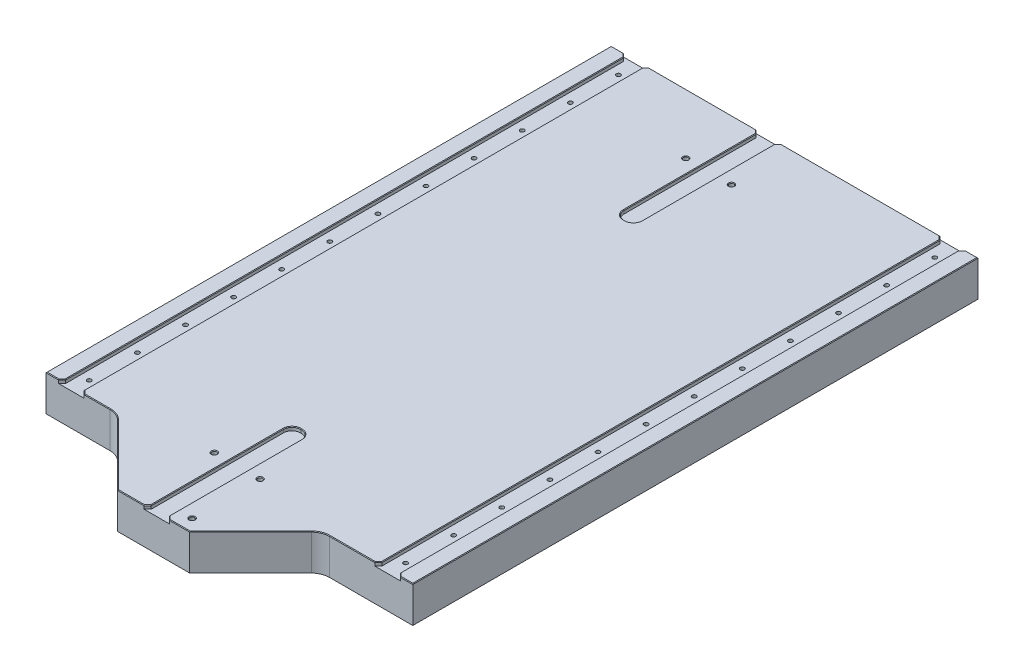
from build123d import *

# Parameters (mm, degrees)
BOSS_EXTRUDE1_DEPTH = 30
SKETCH2_R           = 1.75
SKETCH2_R_2         = 2
CUT_EXTRUDE1_DEPTH  = 31
SKETCH3_W           = 15.25
SKETCH3_H           = 470
CUT_EXTRUDE2_DEPTH  = 3
SKETCH4_W           = 15
SKETCH4_H           = 120
CUT_EXTRUDE3_DEPTH  = 3
FILLET1_R           = 7
FILLET2_R           = 15
CHAMFER1_SIZE       = 3
CHAMFER2_SIZE       = 0.5


with BuildPart() as part:
    # Sketch1 → Boss-Extrude1 (new body)
    with BuildSketch(Plane(origin=(0, 0, 0), x_dir=(1, 0, 0), z_dir=(0, 1, 0))):
        Polygon((-93, -235), (-38, -290), (22, -290), (77, -235), (152.5, -235), (152.5, 235), (-152.5, 235), (-152.5, -235), align=None)
    extrude(amount=BOSS_EXTRUDE1_DEPTH)

    # Sketch2 → Cut-Extrude1 (cut, through all)
    with BuildSketch(Plane(origin=(0, 0, 0), x_dir=(1, 0, 0), z_dir=(0, 1, 0))):
        with Locations((-131.5, 220)):
            Circle(SKETCH2_R)
        with Locations((131.5, 220)):
            Circle(SKETCH2_R)
        with Locations((13.5, -223)):
            Circle(SKETCH2_R_2)
        with Locations((-24.5, -223)):
            Circle(SKETCH2_R_2)
        with Locations((-40.5, 185)):
            Circle(SKETCH2_R_2)
        with Locations((-2.5, 185)):
            Circle(SKETCH2_R_2)
        with Locations((-131.5, 180)):
            Circle(SKETCH2_R)
        with Locations((131.5, 180)):
            Circle(SKETCH2_R)
        with Locations((-131.5, 140)):
            Circle(SKETCH2_R)
        with Locations((131.5, 140)):
            Circle(SKETCH2_R)
        with Locations((-131.5, 100)):
            Circle(SKETCH2_R)
        with Locations((131.5, 100)):
            Circle(SKETCH2_R)
        with Locations((-131.5, 60)):
            Circle(SKETCH2_R)
        with Locations((131.5, 60)):
            Circle(SKETCH2_R)
        with Locations((-131.5, 20)):
            Circle(SKETCH2_R)
        with Locations((131.5, 20)):
            Circle(SKETCH2_R)
        with Locations((-131.5, -20)):
            Circle(SKETCH2_R)
        with Locations((131.5, -20)):
            Circle(SKETCH2_R)
        with Locations((-131.5, -60)):
            Circle(SKETCH2_R)
        with Locations((131.5, -60)):
            Circle(SKETCH2_R)
        with Locations((-131.5, -100)):
            Circle(SKETCH2_R)
        with Locations((131.5, -100)):
            Circle(SKETCH2_R)
        with Locations((-131.5, -140)):
            Circle(SKETCH2_R)
        with Locations((131.5, -140)):
            Circle(SKETCH2_R)
        with Locations((-131.5, -180)):
            Circle(SKETCH2_R)
        with Locations((131.5, -180)):
            Circle(SKETCH2_R)
        with Locations((-131.5, -220)):
            Circle(SKETCH2_R)
        with Locations((131.5, -220)):
            Circle(SKETCH2_R)
        with Locations((13.5, -279.5)):
            Circle(SKETCH2_R_2)
    extrude(amount=CUT_EXTRUDE1_DEPTH, mode=Mode.SUBTRACT)

    # Sketch3 → Cut-Extrude2 (cut)
    with BuildSketch(Plane(origin=(0, 30, 0), x_dir=(1, 0, 0), z_dir=(0, 1, 0))):
        with Locations((-131.5, 0)):
            Rectangle(SKETCH3_W, SKETCH3_H)
        with Locations((131.5, 0)):
            Rectangle(SKETCH3_W, SKETCH3_H)
    extrude(amount=-CUT_EXTRUDE2_DEPTH, mode=Mode.SUBTRACT)

    # Sketch4 → Cut-Extrude3 (cut)
    with BuildSketch(Plane(origin=(0, 30, 0), x_dir=(1, 0, 0), z_dir=(0, 1, 0))):
        with Locations((-5.5, -230)):
            Rectangle(SKETCH4_W, SKETCH4_H)
        with Locations((-21.5, 175)):
            Rectangle(SKETCH4_W, SKETCH4_H)
    extrude(amount=-CUT_EXTRUDE3_DEPTH, mode=Mode.SUBTRACT)

    # Fillet1
    fillet1_edges = [part.edges().sort_by_distance(p)[0] for p in [
        (-13, 28.5, 170),
        (2, 28.5, 170),
        (-29, 28.5, -115),
        (-14, 28.5, -115),
    ]]
    fillet(fillet1_edges, radius=FILLET1_R)

    # Fillet2
    fillet2_edges = [part.edges().sort_by_distance(p)[0] for p in [
        (77, 15, 235),
        (-93, 15, 235),
    ]]
    fillet(fillet2_edges, radius=FILLET2_R)

    # Chamfer1
    chamfer1_edges = [part.edges().sort_by_distance(p)[0] for p in [
        (-123.875, 28.5, -235),
        (-123.875, 28.5, 235),
        (-139.125, 28.5, 235),
        (-139.125, 28.5, -235),
        (123.875, 28.5, 235),
        (123.875, 28.5, -235),
        (139.125, 28.5, -235),
        (139.125, 28.5, 235),
        (-13, 28.5, 290),
        (2, 28.5, 290),
        (-29, 28.5, -235),
        (-14, 28.5, -235),
    ]]
    chamfer(chamfer1_edges, length=CHAMFER1_SIZE)

    # Chamfer2
    chamfer2_edges = [part.edges().sort_by_distance(p)[0] for p in [
        (-152.5, 30, 0),
        (-147.3125, 30, 235),
        (-27, 30, 290),
        (47.303300859, 30, 264.696699141),
        (-21.5, 30, -115),
        (-14, 30, -177),
        (-13, 30, 232),
        (-5.5, 30, 170),
        (-26.949747468, 30, -117.050252532),
        (-16.050252532, 30, -117.050252532),
        (-10.949747468, 30, 172.050252532),
        (-0.050252532, 30, 172.050252532),
        (102.044101718, 30, 235),
        (-63.303300859, 30, 264.696699141),
        (77.47295195, 30, 236.141807012),
        (-93.47295195, 30, 236.141807012),
        (-110.044101718, 30, 235),
        (-139.125, 30, 0),
        (-147.3125, 30, -235),
        (-140.625, 30, -233.5),
        (-140.625, 30, 233.5),
        (-123.875, 30, 0),
        (2, 30, 232),
        (13.5, 30, 290),
        (123.875, 30, 0),
        (54.9375, 30, -235),
        (-29, 30, -177),
        (-76.4375, 30, -235),
        (-14.5, 30, 288.5),
        (3.5, 30, 288.5),
        (-30.5, 30, -233.5),
        (-12.5, 30, -233.5),
        (-122.375, 30, -233.5),
        (122.375, 30, -233.5),
        (122.375, 30, 233.5),
        (-122.375, 30, 233.5),
        (139.125, 30, 0),
        (147.3125, 30, 235),
        (140.625, 30, -233.5),
        (140.625, 30, 233.5),
        (152.5, 30, 0),
        (147.3125, 30, -235),
        (11.5, 30, 223),
        (-26.5, 30, 223),
        (-42.5, 30, -185),
        (-4.5, 30, -185),
        (11.5, 30, 279.5),
    ]]
    chamfer(chamfer2_edges, length=CHAMFER2_SIZE)


solid = part.part
